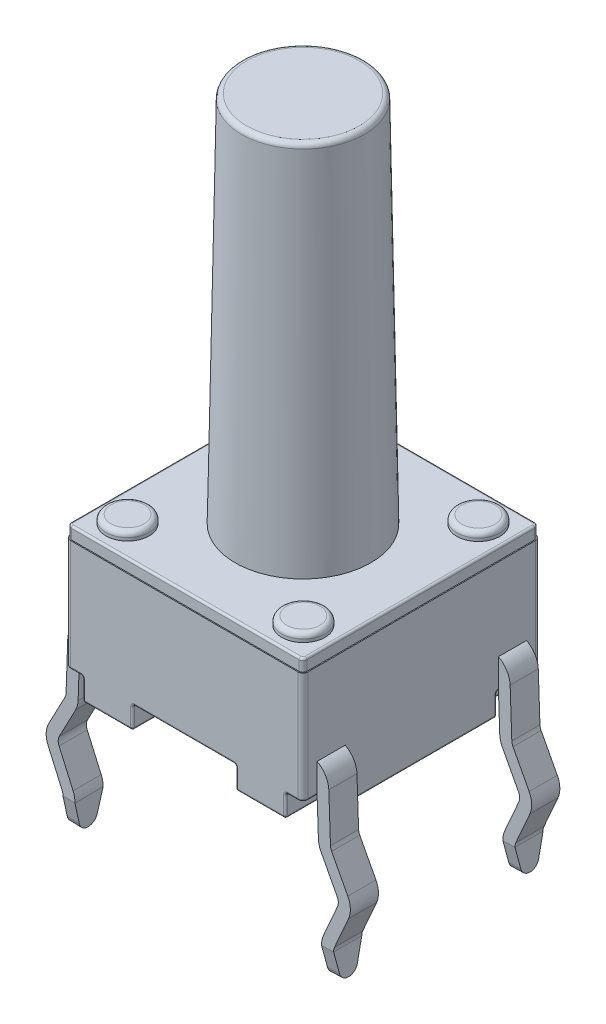
from build123d import *

# Parameters (mm, degrees)
BOSS_EXTRUDE1_START  = 0.5588
SKETCH1_W            = 6.0071
SKETCH1_H            = 6.0071
BOSS_EXTRUDE1_DEPTH  = 2.8194
FILLET1_R            = 0.127
BOSS_EXTRUDE2_DEPTH  = 0.3048
BOSS_EXTRUDE3_REACH  = 7.622
SKETCH4_R            = 0.5461
BOSS_EXTRUDE4_DEPTH  = 0.2032
SKETCH5_R            = 1.7145
BOSS_EXTRUDE5_DEPTH  = 9.4234
BOSS_EXTRUDE5_TAPER  = 1
FILLET2_R            = 0.127
FILLET3_R            = 0.0508
EXTRUDE_THIN1_START  = -0.3556
EXTRUDE_THIN1_DEPTH  = 0.7112
CUT_EXTRUDE1_DEPTH   = 0.7112
MIRROR3_START        = -0.3556
MIRROR3_COPY_1_DEPTH = 0.7112
MIRROR3_COPY_2_DEPTH = 0.7112


with BuildPart() as part:
    # Sketch1 → Boss-Extrude1 (new body)
    with BuildSketch(Plane(origin=(0, 0, 0), x_dir=(1, 0, 0), z_dir=(0, 1, 0)).offset(BOSS_EXTRUDE1_START)):
        Rectangle(SKETCH1_W, SKETCH1_H)
    extrude(amount=BOSS_EXTRUDE1_DEPTH)

    # Fillet1
    fillet1_edges = [part.edges().sort_by_distance(p)[0] for p in [
        (3.00355, 1.9685, 3.00355),
        (-3.00355, 1.9685, 3.00355),
        (-3.00355, 1.9685, -3.00355),
        (3.00355, 1.9685, -3.00355),
    ]]
    fillet(fillet1_edges, radius=FILLET1_R)

    # Sketch2 → Boss-Extrude2 (add)
    with BuildSketch(Plane(origin=(0, 3.3782, 0), x_dir=(-1, 0, 0), z_dir=(0, -1, 0))):
        with BuildLine():
            Line((2.97815, -2.87655), (2.97815, 2.87655))
            ThreePointArc((2.97815, 2.87655), (2.948392049, 2.948392049), (2.87655, 2.97815))
            Line((2.87655, 2.97815), (-2.87655, 2.97815))
            ThreePointArc((-2.87655, 2.97815), (-2.948392049, 2.948392049), (-2.97815, 2.87655))
            Line((-2.97815, 2.87655), (-2.97815, -2.87655))
            ThreePointArc((-2.97815, -2.87655), (-2.948392049, -2.948392049), (-2.87655, -2.97815))
            Line((-2.87655, -2.97815), (2.87655, -2.97815))
            ThreePointArc((2.87655, -2.97815), (2.948392049, -2.948392049), (2.97815, -2.87655))
        make_face()
    extrude(amount=-BOSS_EXTRUDE2_DEPTH)

    # Sketch3 → Boss-Extrude3 (add, up to next)
    with BuildSketch(Plane(origin=(0, 0, 0), x_dir=(1, 0, 0), z_dir=(0, 1, 0)), mode=Mode.PRIVATE) as boss_extrude3_sk1:
        Polygon((-2.566197678, -3.00355), (-2.566197678, -1.89483443), (-3.00355, -1.89483443), (-3.00355, 1.89483443), (-2.566197678, 1.89483443), (-2.566197678, 3.00355), (-1.30175, 3.00355), (-1.30175, 0.560941661), (-2.441300776, 0.560941661), (-2.441300776, -0.560941661), (-1.30175, -0.560941661), (-1.30175, -3.00355), align=None)
    boss_extrude3_tool1 = extrude(boss_extrude3_sk1.sketch, amount=BOSS_EXTRUDE3_REACH, mode=Mode.PRIVATE) - part.part
    # Sketch3 → Boss-Extrude3 (add, up to next)
    with BuildSketch(Plane(origin=(0, 0, 0), x_dir=(1, 0, 0), z_dir=(0, 1, 0)), mode=Mode.PRIVATE) as boss_extrude3_sk2:
        Polygon((2.566197678, 3.00355), (2.566197678, 1.89483443), (3.00355, 1.89483443), (3.00355, -1.89483443), (2.566197678, -1.89483443), (2.566197678, -3.00355), (1.30175, -3.00355), (1.30175, -0.560941661), (2.441300776, -0.560941661), (2.441300776, 0.560941661), (1.30175, 0.560941661), (1.30175, 3.00355), align=None)
    boss_extrude3_tool2 = extrude(boss_extrude3_sk2.sketch, amount=BOSS_EXTRUDE3_REACH, mode=Mode.PRIVATE) - part.part
    add(boss_extrude3_tool1.solids().sort_by_distance((-2.503763, 0, 2.449192))[0])
    add(boss_extrude3_tool2.solids().sort_by_distance((2.503763, 0, -2.449192))[0])

    # Sketch4 → Boss-Extrude4 (add)
    with BuildSketch(Plane(origin=(0, 3.683, 0), x_dir=(1, 0, 0), z_dir=(0, 1, 0))):
        with Locations(Location((2.221694311, 2.212885437, 0), (0, 0, 90))):
            Circle(SKETCH4_R)
        with Locations(Location((-2.221694311, 2.212885437, 0), (0, 0, 90))):
            Circle(SKETCH4_R)
        with Locations(Location((-2.221694311, -2.212885437, 0), (0, 0, 90))):
            Circle(SKETCH4_R)
        with Locations(Location((2.221694311, -2.212885437, 0), (0, 0, 90))):
            Circle(SKETCH4_R)
    extrude(amount=BOSS_EXTRUDE4_DEPTH)

    # Sketch5 → Boss-Extrude5 (add)
    with BuildSketch(Plane(origin=(0, 3.683, 0), x_dir=(1, 0, 0), z_dir=(0, 1, 0))):
        Circle(SKETCH5_R)
    extrude(amount=BOSS_EXTRUDE5_DEPTH, taper=BOSS_EXTRUDE5_TAPER)

    # Fillet2
    fillet2_edges = [part.edges().sort_by_distance(p)[0] for p in [
        (2.221694311, 3.8862, -1.666785437),
        (-2.221694311, 3.8862, -1.666785437),
        (-2.221694311, 3.8862, 2.758985437),
        (2.221694311, 3.8862, 2.758985437),
        (-1.550013941, 13.1064, 0),
    ]]
    fillet(fillet2_edges, radius=FILLET2_R)

    # Fillet3
    fillet3_edges = [part.edges().sort_by_distance(p)[0] for p in [
        (1.30175, 0.5588, -1.782245831),
        (1.30175, 0.2794, -3.00355),
        (1.30175, 0, -1.782245831),
        (1.871525388, 0.5588, -0.560941661),
        (1.30175, 0.2794, -0.560941661),
        (1.871525388, 0, -0.560941661),
        (2.441300776, 0.5588, 0),
        (2.441300776, 0.2794, -0.560941661),
        (2.441300776, 0, 0),
        (1.871525388, 0.5588, 0.560941661),
        (2.441300776, 0.2794, 0.560941661),
        (1.871525388, 0, 0.560941661),
        (1.30175, 0.5588, 1.782245831),
        (1.30175, 0.2794, 0.560941661),
        (1.30175, 0, 1.782245831),
        (1.30175, 0.2794, 3.00355),
        (1.933973839, 0, 3.00355),
        (2.566197678, 0.5588, 2.449192215),
        (2.566197678, 0.2794, 3.00355),
        (2.566197678, 0, 2.449192215),
        (2.784873839, 0.5588, 1.89483443),
        (2.566197678, 0.2794, 1.89483443),
        (2.784873839, 0, 1.89483443),
        (3.00355, 0.2794, 1.89483443),
        (3.00355, 0, 0),
        (2.784873839, 0.5588, -1.89483443),
        (3.00355, 0.2794, -1.89483443),
        (2.784873839, 0, -1.89483443),
        (2.566197678, 0.2794, -3.00355),
        (1.933973839, 0, -3.00355),
        (2.566197678, 0.5588, -2.449192215),
        (2.566197678, 0.2794, -1.89483443),
        (2.566197678, 0, -2.449192215),
        (-2.721373839, 0.5588, 3.00355),
        (3.00355, 0.5588, 2.385692215),
        (-3.00355, 0.5588, -2.385692215),
        (2.721373839, 0.5588, -3.00355),
        (2.966352561, 0.5588, 2.966352561),
        (2.966352561, 0.5588, -2.966352561),
        (-2.966352561, 0.5588, -2.966352561),
        (-2.966352561, 0.5588, 2.966352561),
        (-2.948392049, 3.683, 2.948392049),
        (0, 3.683, 2.97815),
        (2.948392049, 3.683, 2.948392049),
        (2.97815, 3.683, 0),
        (2.948392049, 3.683, -2.948392049),
        (0, 3.683, -2.97815),
        (-2.948392049, 3.683, -2.948392049),
        (-2.97815, 3.683, 0),
        (0, 0.5588, 3.00355),
        (-3.00355, 0.5588, 2.385692215),
        (-2.721373839, 0.5588, -3.00355),
        (-1.30175, 0.5588, 1.782245831),
        (-1.30175, 0.2794, 3.00355),
        (-1.30175, 0, 1.782245831),
        (-1.871525388, 0.5588, 0.560941661),
        (-1.30175, 0.2794, 0.560941661),
        (-1.871525388, 0, 0.560941661),
        (-2.441300776, 0.5588, 0),
        (-2.441300776, 0.2794, 0.560941661),
        (-2.441300776, 0, 0),
        (-1.871525388, 0.5588, -0.560941661),
        (-2.441300776, 0.2794, -0.560941661),
        (-1.871525388, 0, -0.560941661),
        (-1.30175, 0.5588, -1.782245831),
        (-1.30175, 0.2794, -0.560941661),
        (-1.30175, 0, -1.782245831),
        (-1.30175, 0.2794, -3.00355),
        (-1.933973839, 0, -3.00355),
        (-2.566197678, 0.5588, -2.449192215),
        (-2.566197678, 0.2794, -3.00355),
        (-2.566197678, 0, -2.449192215),
        (-2.784873839, 0.5588, -1.89483443),
        (-2.566197678, 0.2794, -1.89483443),
        (-2.784873839, 0, -1.89483443),
        (-3.00355, 0.2794, -1.89483443),
        (-3.00355, 0, 0),
        (-2.784873839, 0.5588, 1.89483443),
        (-3.00355, 0.2794, 1.89483443),
        (-2.784873839, 0, 1.89483443),
        (-2.566197678, 0.2794, 3.00355),
        (-1.933973839, 0, 3.00355),
        (-2.566197678, 0.5588, 2.449192215),
        (-2.566197678, 0.2794, 1.89483443),
        (-2.566197678, 0, 2.449192215),
        (0, 0.5588, -3.00355),
        (3.00355, 0.5588, -2.385692215),
        (2.721373839, 0.5588, 3.00355),
    ]]
    fillet(fillet3_edges, radius=FILLET3_R)

    # Sketch6 → Extrude-Thin1 (add)
    with BuildSketch(Plane.XY.offset(3.00355).offset(EXTRUDE_THIN1_START)):
        with BuildLine():
            Line((-2.526489479, 1.064092226), (-2.74199854, 1.064092226))
            ThreePointArc((-2.74199854, 1.064092226), (-2.918441767, 0.992804535), (-2.995843811, 0.818956698))
            Line((-2.995843811, 0.818956698), (-3.03780929, -0.382777412))
            ThreePointArc((-3.03780929, -0.382777412), (-3.056264298, -0.506985303), (-3.10198813, -0.623936226))
            Line((-3.10198813, -0.623936226), (-3.511410555, -1.400308198))
            ThreePointArc((-3.511410555, -1.400308198), (-3.540582755, -1.509925841), (-3.519128157, -1.62131141))
            Line((-3.519128157, -1.62131141), (-3.164860036, -2.424352043))
            ThreePointArc((-3.164860036, -2.424352043), (-3.127405669, -2.544207613), (-3.117659921, -2.669400296))
            Line((-3.117659921, -2.669400296), (-3.142411752, -3.3782))
            Line((-3.142411752, -3.3782), (-3.447026076, -3.367562633))
            Line((-3.447026076, -3.367562633), (-3.422274245, -2.658762929))
            ThreePointArc((-3.422274245, -2.658762929), (-3.42670413, -2.601857165), (-3.443728843, -2.54737736))
            Line((-3.443728843, -2.54737736), (-3.797996964, -1.744336727))
            ThreePointArc((-3.797996964, -1.744336727), (-3.845197079, -1.499288474), (-3.781018239, -1.25812966))
            Line((-3.781018239, -1.25812966), (-3.371595814, -0.481757688))
            ThreePointArc((-3.371595814, -0.481757688), (-3.350812254, -0.428598178), (-3.342423614, -0.372140046))
            Line((-3.342423614, -0.372140046), (-3.300458135, 0.829594065))
            ThreePointArc((-3.300458135, 0.829594065), (-3.130173638, 1.212059307), (-2.74199854, 1.368892226))
            Line((-2.74199854, 1.368892226), (-2.526489479, 1.368892226))
            Line((-2.526489479, 1.368892226), (-2.526489479, 1.064092226))
        make_face()
    extrude_thin1 = extrude(amount=-EXTRUDE_THIN1_DEPTH)

    # Sketch9 → Cut-Extrude1 (cut)
    with BuildSketch(Plane(origin=(-3.325373038, 0.116124585, 0), x_dir=(0, 0, 1), z_dir=(-0.9993908270190957, 0.03489949670250484, 0))):
        with BuildLine():
            Line((2.64795, -3.48581068), (2.64795, -2.776578932))
            Line((2.64795, -2.776578932), (2.517535772, -3.30911696))
            ThreePointArc((2.517535772, -3.30911696), (2.435466476, -3.436364343), (2.29235, -3.48581068))
            Line((2.29235, -3.48581068), (2.64795, -3.48581068))
        make_face()
        with BuildLine():
            Line((1.93675, -3.48581068), (2.29235, -3.48581068))
            ThreePointArc((2.29235, -3.48581068), (2.149233524, -3.436364343), (2.067164228, -3.30911696))
            Line((2.067164228, -3.30911696), (1.93675, -2.776578932))
            Line((1.93675, -2.776578932), (1.93675, -3.48581068))
        make_face()
    cut_extrude1 = extrude(amount=-CUT_EXTRUDE1_DEPTH, mode=Mode.SUBTRACT)

    # Mirror1: Extrude-Thin1, Cut-Extrude1 across plane
    add(extrude_thin1.mirror(Plane.XY))
    add(cut_extrude1.mirror(Plane.XY), mode=Mode.SUBTRACT)

    # Mirror3: Extrude-Thin1, Cut-Extrude1 across plane
    add(extrude_thin1.mirror(Plane(origin=(0, 0, 0), x_dir=(0, 0, 1), z_dir=(1, 0, 0))))
    add(cut_extrude1.mirror(Plane(origin=(0, 0, 0), x_dir=(0, 0, 1), z_dir=(1, 0, 0))), mode=Mode.SUBTRACT)

    # Mirror3 copy 1 sketch → Mirror3 copy 1 (add)
    with BuildSketch(Plane(origin=(0, 0, -3.00355), x_dir=(-1, 0, 0), z_dir=(0, 0, -1)).offset(MIRROR3_START)):
        with BuildLine():
            Line((-2.526489479, 1.064092226), (-2.74199854, 1.064092226))
            ThreePointArc((-2.74199854, 1.064092226), (-2.918441767, 0.992804535), (-2.995843811, 0.818956698))
            Line((-2.995843811, 0.818956698), (-3.03780929, -0.382777412))
            ThreePointArc((-3.03780929, -0.382777412), (-3.056264298, -0.506985303), (-3.10198813, -0.623936226))
            Line((-3.10198813, -0.623936226), (-3.511410555, -1.400308198))
            ThreePointArc((-3.511410555, -1.400308198), (-3.540582755, -1.509925841), (-3.519128157, -1.62131141))
            Line((-3.519128157, -1.62131141), (-3.164860036, -2.424352043))
            ThreePointArc((-3.164860036, -2.424352043), (-3.127405669, -2.544207613), (-3.117659921, -2.669400296))
            Line((-3.117659921, -2.669400296), (-3.142411752, -3.3782))
            Line((-3.142411752, -3.3782), (-3.447026076, -3.367562633))
            Line((-3.447026076, -3.367562633), (-3.422274245, -2.658762929))
            ThreePointArc((-3.422274245, -2.658762929), (-3.42670413, -2.601857165), (-3.443728843, -2.54737736))
            Line((-3.443728843, -2.54737736), (-3.797996964, -1.744336727))
            ThreePointArc((-3.797996964, -1.744336727), (-3.845197079, -1.499288474), (-3.781018239, -1.25812966))
            Line((-3.781018239, -1.25812966), (-3.371595814, -0.481757688))
            ThreePointArc((-3.371595814, -0.481757688), (-3.350812254, -0.428598178), (-3.342423614, -0.372140046))
            Line((-3.342423614, -0.372140046), (-3.300458135, 0.829594065))
            ThreePointArc((-3.300458135, 0.829594065), (-3.130173638, 1.212059307), (-2.74199854, 1.368892226))
            Line((-2.74199854, 1.368892226), (-2.526489479, 1.368892226))
            Line((-2.526489479, 1.368892226), (-2.526489479, 1.064092226))
        make_face()
    extrude(amount=-MIRROR3_COPY_1_DEPTH)

    # Mirror3 copy 2 sketch → Mirror3 copy 2 (cut)
    with BuildSketch(Plane(origin=(3.325373038, 0.116124585, 0), x_dir=(0, 0, -1), z_dir=(0.9993908270190957, 0.03489949670250484, 0))):
        with BuildLine():
            Line((2.64795, -3.48581068), (2.64795, -2.776578932))
            Line((2.64795, -2.776578932), (2.517535772, -3.30911696))
            ThreePointArc((2.517535772, -3.30911696), (2.435466476, -3.436364343), (2.29235, -3.48581068))
            Line((2.29235, -3.48581068), (2.64795, -3.48581068))
        make_face()
        with BuildLine():
            Line((1.93675, -3.48581068), (2.29235, -3.48581068))
            ThreePointArc((2.29235, -3.48581068), (2.149233524, -3.436364343), (2.067164228, -3.30911696))
            Line((2.067164228, -3.30911696), (1.93675, -2.776578932))
            Line((1.93675, -2.776578932), (1.93675, -3.48581068))
        make_face()
    extrude(amount=-MIRROR3_COPY_2_DEPTH, mode=Mode.SUBTRACT)


solid = part.part
